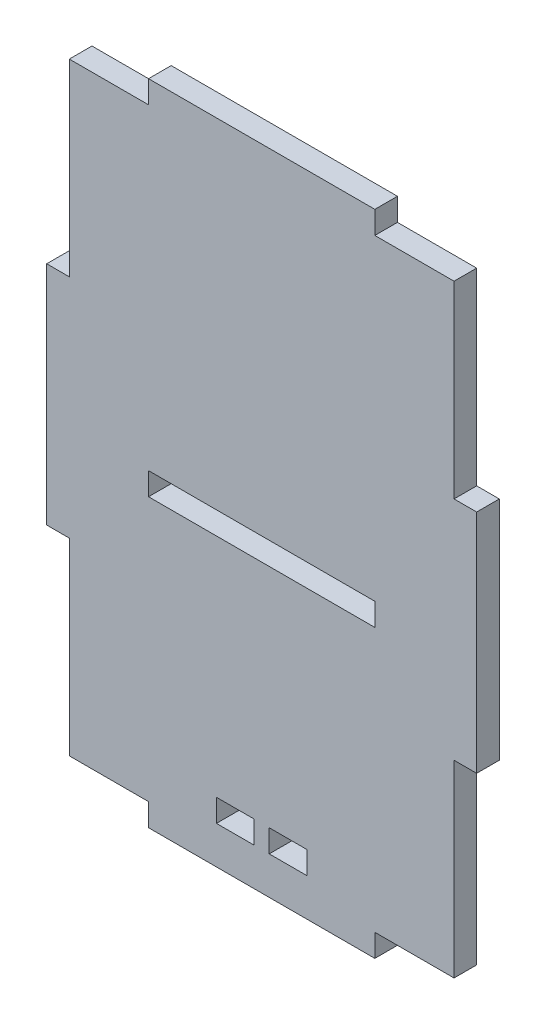
from build123d import *

# Parameters (mm, degrees)
SKETCH1_W           = 30
SKETCH1_H           = 3
SKETCH1_W_2         = 5
BOSS_EXTRUDE1_DEPTH = 1.5


with BuildPart() as part:
    # Sketch1 → Boss-Extrude1 (new body, symmetric)
    with BuildSketch(Plane.XY):
        Polygon((-25.5, -15), (-25.5, -40), (-15, -40), (-15, -43), (15, -43), (15, -40), (25.5, -40), (25.5, -15), (28.5, -15), (28.5, 15), (25.5, 15), (25.5, 40), (15, 40), (15, 43), (-15, 43), (-15, 40), (-25.5, 40), (-25.5, 15), (-28.5, 15), (-28.5, -15), align=None)
        with Locations((0, -3.5)):
            Rectangle(SKETCH1_W, SKETCH1_H, mode=Mode.SUBTRACT)
        with Locations((3.5, -36.5)):
            Rectangle(SKETCH1_W_2, SKETCH1_H, mode=Mode.SUBTRACT)
        with Locations((-3.5, -36.5)):
            Rectangle(SKETCH1_W_2, SKETCH1_H, mode=Mode.SUBTRACT)
    extrude(amount=BOSS_EXTRUDE1_DEPTH, both=True)


solid = part.part
